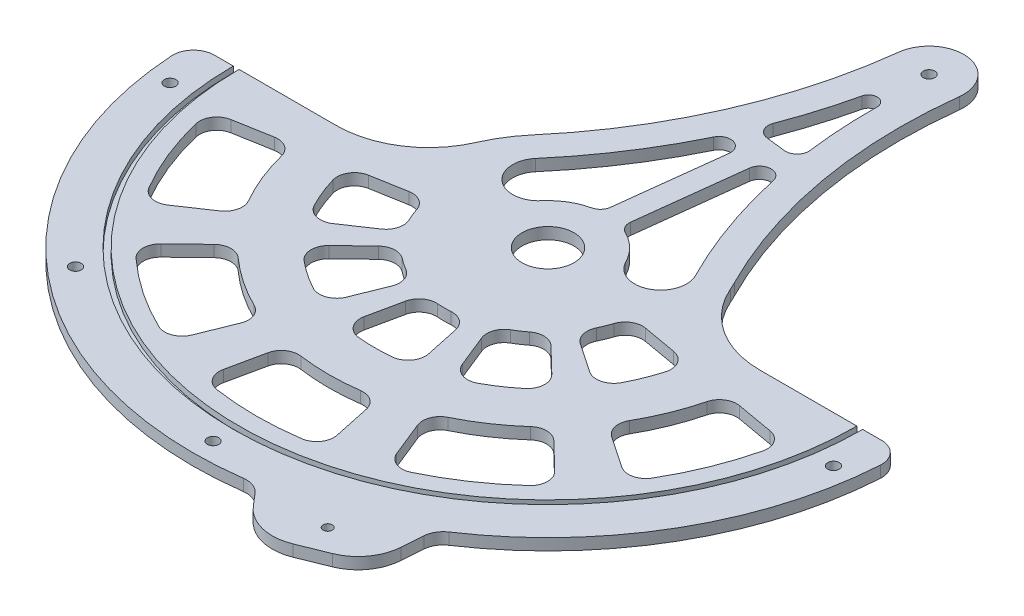
from build123d import *

# Parameters (mm, degrees)
BOSS_EXTRUDE1_DEPTH = 3.175
CUT_EXTRUDE1_DEPTH  = 7.35
CUT_EXTRUDE2_DEPTH  = 3.175
BOSS_EXTRUDE2_DEPTH = 3.175
SKETCH6_R           = 14.2875
CUT_EXTRUDE3_DEPTH  = 7.35
BOSS_EXTRUDE3_DEPTH = 6.35
SKETCH8_R           = 2.54
CUT_EXTRUDE4_DEPTH  = 7.35
SKETCH9_R           = 3.175
CUT_EXTRUDE5_DEPTH  = 7.35
FILLET1_R           = 25.4
FILLET2_R           = 9.525
FILLET4_R           = 11.43
FILLET3_R           = 50.8
SKETCH10_R          = 3.175
BOSS_EXTRUDE4_DEPTH = 6.35
CUT_EXTRUDE8_DEPTH  = 7.35


with BuildPart() as part:
    # Sketch1 → Boss-Extrude1 (new body, symmetric)
    with BuildSketch(Plane(origin=(0, 0, 0), x_dir=(1, 0, 0), z_dir=(0, 1, 0))):
        with BuildLine():
            Line((76.2, 0), (173.0375, 0))
            ThreePointArc((173.0375, 0), (0, -173.0375), (-173.0375, 0))
            Line((-173.0375, 0), (-76.2, 0))
            ThreePointArc((-76.2, 0), (0, 76.2), (76.2, 0))
        make_face()
    extrude(amount=BOSS_EXTRUDE1_DEPTH, both=True)

    # Sketch2 → Cut-Extrude1 (cut, through all)
    with BuildSketch(Plane(origin=(0, 3.175, 0), x_dir=(1, 0, 0), z_dir=(0, 1, 0))):
        with BuildLine():
            Line((-78.965828786, -53.263124056), (-47.379497272, -31.957874433))
            ThreePointArc((-47.379497272, -31.957874433), (-52.988557288, -21.408766814), (-56.281763085, -9.923993354))
            Line((-56.281763085, -9.923993354), (-93.802938474, -16.539988923))
            ThreePointArc((-93.802938474, -16.539988923), (-88.314262147, -35.681278023), (-78.965828786, -53.263124056))
        make_face()
        with BuildLine():
            Line((-60.063484672, -148.662341282), (-45.196285496, -111.864732053))
            ThreePointArc((-45.196285496, -111.864732053), (-67.466623804, -100.023383129), (-86.788346911, -83.810532396))
            Line((-86.788346911, -83.810532396), (-115.337145237, -111.379786473))
            ThreePointArc((-115.337145237, -111.379786473), (-89.65959216, -132.92581179), (-60.063484672, -148.662341282))
        make_face()
        with BuildLine():
            Line((-35.681278023, -88.314262147), (-21.408766814, -52.988557288))
            ThreePointArc((-21.408766814, -52.988557288), (-31.957874433, -47.379497272), (-41.110269589, -39.699725872))
            Line((-41.110269589, -39.699725872), (-68.517115982, -66.166209786))
            ThreePointArc((-68.517115982, -66.166209786), (-53.263124056, -78.965828786), (-35.681278023, -88.314262147))
        make_face()
        with BuildLine():
            Line((-132.92581179, -89.65959216), (-100.023383129, -67.466623804))
            ThreePointArc((-100.023383129, -67.466623804), (-111.864732053, -45.196285496), (-118.817055401, -20.950652636))
            Line((-118.817055401, -20.950652636), (-157.901613099, -27.842314687))
            ThreePointArc((-157.901613099, -27.842314687), (-148.662341282, -60.063484672), (-132.92581179, -89.65959216))
        make_face()
        with BuildLine():
            Line((33.336040726, -156.833740933), (25.084545497, -118.013508029))
            ThreePointArc((25.084545497, -118.013508029), (0, -120.65), (-25.084545497, -118.013508029))
            Line((-25.084545497, -118.013508029), (-33.336040726, -156.833740933))
            ThreePointArc((-33.336040726, -156.833740933), (0, -160.3375), (33.336040726, -156.833740933))
        make_face()
        with BuildLine():
            Line((19.80358855, -93.16855897), (11.88215313, -55.901135382))
            ThreePointArc((11.88215313, -55.901135382), (0, -57.15), (-11.88215313, -55.901135382))
            Line((-11.88215313, -55.901135382), (-19.80358855, -93.16855897))
            ThreePointArc((-19.80358855, -93.16855897), (0, -95.25), (19.80358855, -93.16855897))
        make_face()
        with BuildLine():
            Line((115.337145237, -111.379786473), (86.788346911, -83.810532396))
            ThreePointArc((86.788346911, -83.810532396), (67.466623804, -100.023383129), (45.196285496, -111.864732053))
            Line((45.196285496, -111.864732053), (60.063484672, -148.662341282))
            ThreePointArc((60.063484672, -148.662341282), (89.65959216, -132.92581179), (115.337145237, -111.379786473))
        make_face()
        with BuildLine():
            Line((68.517115982, -66.166209786), (41.110269589, -39.699725872))
            ThreePointArc((41.110269589, -39.699725872), (31.957874433, -47.379497272), (21.408766814, -52.988557288))
            Line((21.408766814, -52.988557288), (35.681278023, -88.314262147))
            ThreePointArc((35.681278023, -88.314262147), (53.263124056, -78.965828786), (68.517115982, -66.166209786))
        make_face()
        with BuildLine():
            Line((157.901613099, -27.842314687), (118.817055401, -20.950652636))
            ThreePointArc((118.817055401, -20.950652636), (111.864732053, -45.196285496), (100.023383129, -67.466623804))
            Line((100.023383129, -67.466623804), (132.92581179, -89.65959216))
            ThreePointArc((132.92581179, -89.65959216), (148.662341282, -60.063484672), (157.901613099, -27.842314687))
        make_face()
        with BuildLine():
            Line((93.802938474, -16.539988923), (56.281763085, -9.923993354))
            ThreePointArc((56.281763085, -9.923993354), (52.988557288, -21.408766814), (47.379497272, -31.957874433))
            Line((47.379497272, -31.957874433), (78.965828786, -53.263124056))
            ThreePointArc((78.965828786, -53.263124056), (88.314262147, -35.681278023), (93.802938474, -16.539988923))
        make_face()
    extrude(amount=-CUT_EXTRUDE1_DEPTH, mode=Mode.SUBTRACT)

    # Sketch5 → Cut-Extrude2 (cut)
    with BuildSketch(Plane(origin=(0, 3.175, 0), x_dir=(1, 0, 0), z_dir=(0, 1, 0))):
        with BuildLine():
            Line((169.8625, 0), (173.0375, 0))
            ThreePointArc((173.0375, 0), (0, -173.0375), (-173.0375, 0))
            Line((-173.0375, 0), (-169.8625, 0))
            ThreePointArc((-169.8625, 0), (0, -169.8625), (169.8625, 0))
        make_face()
    extrude(amount=-CUT_EXTRUDE2_DEPTH, mode=Mode.SUBTRACT)

    # Sketch4 → Boss-Extrude2 (add, symmetric)
    with BuildSketch(Plane(origin=(0, 0, 0), x_dir=(1, 0, 0), z_dir=(0, 1, 0))):
        with BuildLine():
            Line((173.0375, 0), (195.2625, 0))
            ThreePointArc((195.2625, 0), (0, -195.2625), (-195.2625, 0))
            Line((-195.2625, 0), (-173.0375, 0))
            ThreePointArc((-173.0375, 0), (0, -173.0375), (173.0375, 0))
        make_face()
    extrude(amount=BOSS_EXTRUDE2_DEPTH, both=True)

    # Sketch6 → Cut-Extrude3 (cut, through all)
    with BuildSketch(Plane(origin=(0, 3.175, 0), x_dir=(1, 0, 0), z_dir=(0, 1, 0))):
        Circle(SKETCH6_R)
    extrude(amount=-CUT_EXTRUDE3_DEPTH, mode=Mode.SUBTRACT)

    # Sketch7 → Boss-Extrude3 (add, through all)
    with BuildSketch(Plane(origin=(0, 3.175, 0), x_dir=(1, 0, 0), z_dir=(0, 1, 0))):
        Polygon((32.206866836, -192.588062026), (53.968732111, -217.988062026), (101.069671923, -198.95804708), (103.466206527, -165.596461355), align=None)
    extrude(amount=-BOSS_EXTRUDE3_DEPTH)

    # Sketch8 → Cut-Extrude4 (cut, through all)
    with BuildSketch(Plane(origin=(0, 3.175, 0), x_dir=(-1, 0, 0), z_dir=(0, 1, 0))):
        with Locations((-72.677869349, 193.782658122)):
            Circle(SKETCH8_R)
    extrude(amount=-CUT_EXTRUDE4_DEPTH, mode=Mode.SUBTRACT)

    # Sketch9 → Cut-Extrude5 (cut, through all)
    with BuildSketch(Plane(origin=(0, 3.175, 0), x_dir=(1, 0, 0), z_dir=(0, 1, 0))):
        with Locations((-182.389864028, -25.4)):
            Circle(SKETCH9_R)
        with Locations((-120.900398056, -138.903982124)):
            Circle(SKETCH9_R)
        with Locations((0, -184.15)):
            Circle(SKETCH9_R)
        with Locations((182.389864028, -25.4)):
            Circle(SKETCH9_R)
    extrude(amount=-CUT_EXTRUDE5_DEPTH, mode=Mode.SUBTRACT)

    # Fillet1
    fillet1_edges = [part.edges().sort_by_distance(p)[0] for p in [
        (53.968732111, 0, 217.988062026),
        (101.069671923, 0, 198.95804708),
    ]]
    fillet(fillet1_edges, radius=FILLET1_R)

    # Fillet2
    fillet2_edges = [part.edges().sort_by_distance(p)[0] for p in [
        (-35.681278023, 0, 88.314262147),
        (-68.517115982, 0, 66.166209786),
        (-41.110269589, 0, 39.699725872),
        (-21.408766814, 0, 52.988557288),
        (33.336040726, 0, 156.833740933),
        (-33.336040726, 0, 156.833740933),
        (-25.084545497, 0, 118.013508029),
        (25.084545497, 0, 118.013508029),
        (-132.92581179, 0, 89.65959216),
        (-157.901613099, 0, 27.842314687),
        (-118.817055401, 0, 20.950652636),
        (-100.023383129, 0, 67.466623804),
        (19.80358855, 0, 93.16855897),
        (-19.80358855, 0, 93.16855897),
        (-11.88215313, 0, 55.901135382),
        (11.88215313, 0, 55.901135382),
        (115.337145237, 0, 111.379786473),
        (60.063484672, 0, 148.662341282),
        (45.196285496, 0, 111.864732053),
        (86.788346911, 0, 83.810532396),
        (93.802938474, 0, 16.539988923),
        (78.965828786, 0, 53.263124056),
        (47.379497272, 0, 31.957874433),
        (56.281763085, 0, 9.923993354),
        (157.901613099, 0, 27.842314687),
        (132.92581179, 0, 89.65959216),
        (100.023383129, 0, 67.466623804),
        (118.817055401, 0, 20.950652636),
        (68.517115982, 0, 66.166209786),
        (35.681278023, 0, 88.314262147),
        (21.408766814, 0, 52.988557288),
        (41.110269589, 0, 39.699725872),
        (-78.965828786, 0, 53.263124056),
        (-93.802938474, 0, 16.539988923),
        (-56.281763085, 0, 9.923993354),
        (-47.379497272, 0, 31.957874433),
        (-60.063484672, 0, 148.662341282),
        (-115.337145237, 0, 111.379786473),
        (-86.788346911, 0, 83.810532396),
        (-45.196285496, 0, 111.864732053),
    ]]
    fillet(fillet2_edges, radius=FILLET2_R)

    # Fillet4
    fillet4_edges = [part.edges().sort_by_distance(p)[0] for p in [
        (-195.2625, 0, 0),
        (195.2625, 0, 0),
        (32.206866836, 0, 192.588062026),
        (103.466206527, 0, 165.596461355),
    ]]
    fillet(fillet4_edges, radius=FILLET4_R)

    # Fillet3
    fillet3_edges = [part.edges().sort_by_distance(p)[0] for p in [
        (-76.2, 0, 0),
        (76.2, 0, 0),
    ]]
    fillet(fillet3_edges, radius=FILLET3_R)

    # Sketch10 → Boss-Extrude4 (add, through all)
    with BuildSketch(Plane(origin=(0, 3.175, 0), x_dir=(1, 0, 0), z_dir=(0, 1, 0))):
        with BuildLine():
            ThreePointArc((67.928946778, 34.526774967), (8.977711779, 75.669284992), (-57.964030941, 49.46322995))
            ThreePointArc((-57.964030941, 49.46322995), (-16.949469571, 114.97748152), (3.307679425, 189.569433618))
            ThreePointArc((3.307679425, 189.569433618), (24.469427945, 206.242321248), (41.142321921, 185.080577729))
            ThreePointArc((41.142321921, 185.080577729), (43.382996969, 107.81939227), (67.928946778, 34.526774967))
        make_face()
        with Locations((22.225, 187.325)):
            Circle(SKETCH10_R, mode=Mode.SUBTRACT)
    extrude(amount=-BOSS_EXTRUDE4_DEPTH)

    # Sketch12 → Cut-Extrude8 (cut, through all)
    with BuildSketch(Plane(origin=(0, 3.175, 0), x_dir=(1, 0, 0), z_dir=(0, 1, 0))):
        with BuildLine():
            Line((-2.07363983, 36.418985679), (4.850539481, 94.779925592))
            ThreePointArc((4.850539481, 94.779925592), (0.333088399, 101.621047974), (-7.165084652, 98.306576579))
            ThreePointArc((-7.165084652, 98.306576579), (-24.649508535, 67.503565311), (-45.888191161, 39.158390377))
            ThreePointArc((-45.888191161, 39.158390377), (-44.294290976, 19.01577896), (-24.151679559, 20.609679146))
            ThreePointArc((-24.151679559, 20.609679146), (-16.406925901, 27.182260437), (-6.98284465, 30.972606939))
            ThreePointArc((-6.98284465, 30.972606939), (-3.662711233, 32.915632241), (-2.07363983, 36.418985679))
        make_face()
        with BuildLine():
            Line((10.537907668, 34.922700382), (17.46208698, 93.283640295))
            ThreePointArc((17.46208698, 93.283640295), (23.454908284, 98.877781208), (29.96934923, 93.900796288))
            ThreePointArc((29.96934923, 93.900796288), (39.760639727, 59.861683314), (53.777082866, 27.333696849))
            ThreePointArc((53.777082866, 27.333696849), (47.514175651, 8.123249021), (28.303727824, 14.386156236))
            ThreePointArc((28.303727824, 14.386156236), (22.311931109, 22.588497741), (14.036401181, 28.478798112))
            ThreePointArc((14.036401181, 28.478798112), (11.263098352, 31.144773477), (10.537907668, 34.922700382))
        make_face()
        with BuildLine():
            Line((7.885230455, 112.532807169), (18.665718923, 111.253766164))
            ThreePointArc((18.665718923, 111.253766164), (23.92581315, 113.09134196), (25.712045825, 118.369092324))
            ThreePointArc((25.712045825, 118.369092324), (23.896495136, 137.880350524), (23.452109252, 157.47085695))
            ThreePointArc((23.452109252, 157.47085695), (19.251080744, 162.259109129), (14.046257475, 158.586805466))
            ThreePointArc((14.046257475, 158.586805466), (9.030141141, 139.644155235), (2.699469968, 121.099397934))
            ThreePointArc((2.699469968, 121.099397934), (3.201149498, 115.550200359), (7.885230455, 112.532807169))
        make_face()
    extrude(amount=-CUT_EXTRUDE8_DEPTH, mode=Mode.SUBTRACT)


solid = part.part
